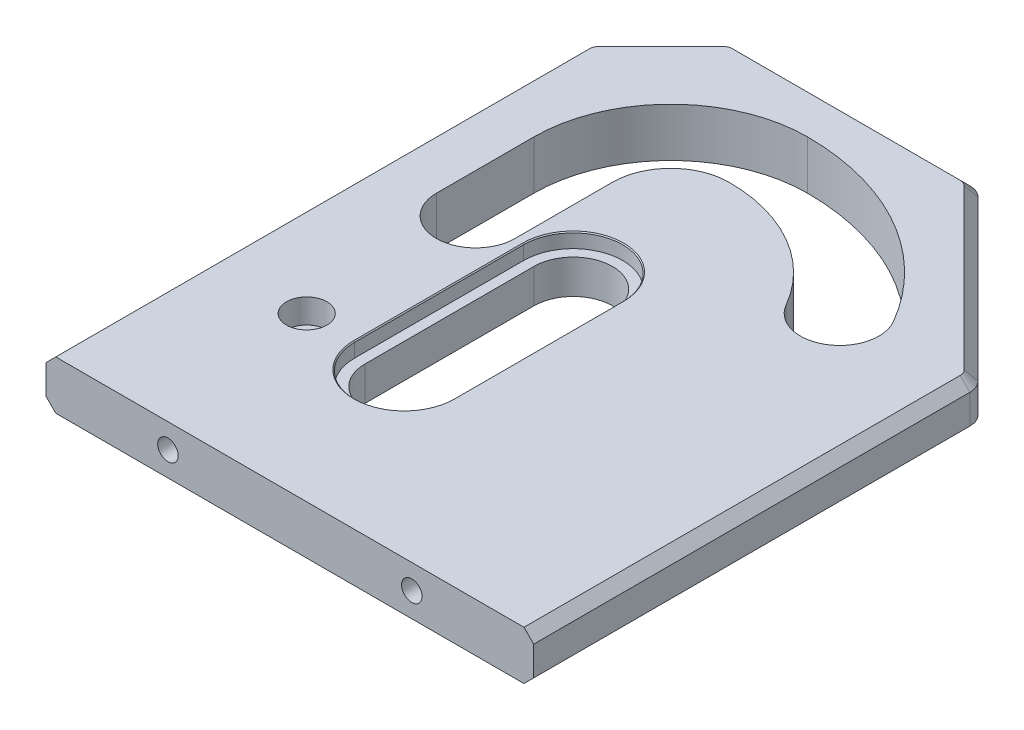
from build123d import *

# Parameters (mm, degrees)
SKETCH1_W                 = 100
SKETCH1_H                 = 126.094412
BOSS_EXTRUDE1_DEPTH       = 5
SLOTS_DEPTH               = 11
CUT_EXTRUDE5_DEPTH        = 3
CHAMFER2_SIZE             = 0.2
M5X0_8_TAPPED_HOLE2_D     = 4.2
SKETCH10_R                = 4.15
CUT_EXTRUDE4_DEPTH        = 5
M5X0_8_TAPPED_HOLE1_D     = 4.2
M5X0_8_TAPPED_HOLE1_DEPTH = 20
M5X0_8_TAPPED_HOLE1_TIP   = 1.2618073
CUT_EXTRUDE2_DEPTH        = 11
CUT_EXTRUDE3_DEPTH        = 11
FILLET1_R                 = 4
CHAMFER1_SIZE             = 2


with BuildPart() as part:
    # Sketch1 → Boss-Extrude1 (new body, symmetric)
    with BuildSketch(Plane(origin=(0, 0, 0), x_dir=(1, 0, 0), z_dir=(0, 1, 0))):
        with Locations((10, -5.047206)):
            Rectangle(SKETCH1_W, SKETCH1_H)
    extrude(amount=BOSS_EXTRUDE1_DEPTH, both=True)

    # Sketch3 → Slots (cut, through all)
    with BuildSketch(Plane(origin=(0, 5, 0), x_dir=(1, 0, 0), z_dir=(0, 1, 0))):
        with BuildLine():
            Line((-8.05, 0), (-8.05, -34.641016151))
            ThreePointArc((-8.05, -34.641016151), (0, -42.691016151), (8.05, -34.641016151))
            Line((8.05, -34.641016151), (8.05, 0))
            ThreePointArc((8.05, 0), (0, 8.05), (-8.05, 0))
        make_face()
        with BuildLine():
            Line((-11.95, 0), (-11.95, 20))
            ThreePointArc((-11.95, 20), (-8.449926035, 28.449926035), (0, 31.95))
            ThreePointArc((0, 31.95), (15.975, 27.669511651), (27.669511651, 15.975))
            ThreePointArc((27.669511651, 15.975), (38.666016151, 13.0284955), (41.612520652, 24.025))
            ThreePointArc((41.612520652, 24.025), (24.025, 41.612520652), (0, 48.05))
            ThreePointArc((0, 48.05), (-19.834345212, 39.834345212), (-28.05, 20))
            Line((-28.05, 20), (-28.05, 0))
            ThreePointArc((-28.05, 0), (-20, -8.05), (-11.95, 0))
        make_face()
    extrude(amount=-SLOTS_DEPTH, mode=Mode.SUBTRACT)

    # Sketch11 → Cut-Extrude5 (cut)
    with BuildSketch(Plane(origin=(0, 5, 0), x_dir=(1, 0, 0), z_dir=(0, 1, 0))):
        with BuildLine():
            Line((-10.15, 0), (-10.15, -34.641016151))
            ThreePointArc((-10.15, -34.641016151), (0, -44.791016151), (10.15, -34.641016151))
            Line((10.15, -34.641016151), (10.15, 0))
            ThreePointArc((10.15, 0), (0, 10.15), (-10.15, 0))
        make_face()
    extrude(amount=-CUT_EXTRUDE5_DEPTH, mode=Mode.SUBTRACT)

    # Chamfer2
    chamfer2_edges = [part.edges().sort_by_distance(p)[0] for p in [
        (0, 5, -10.15),
        (-10.15, 5, 17.320508076),
        (0, 5, 44.791016151),
        (10.15, 5, 17.320508076),
    ]]
    chamfer(chamfer2_edges, length=CHAMFER2_SIZE)

    # M5x0.8 Tapped Hole2 (through all)
    with Locations(Plane(origin=(0, 5, 0), x_dir=(1, 0, 0), z_dir=(0, 1, 0))):
        with Locations((-20, -34.641016151)):
            Hole(M5X0_8_TAPPED_HOLE2_D / 2)

    # Sketch10 → Cut-Extrude4 (cut)
    with BuildSketch(Plane(origin=(0, 5, 0), x_dir=(1, 0, 0), z_dir=(0, 1, 0))):
        with Locations((-20, -34.641016151)):
            Circle(SKETCH10_R)
    extrude(amount=-CUT_EXTRUDE4_DEPTH, mode=Mode.SUBTRACT)

    # M5x0.8 Tapped Hole1
    with Locations(Plane.XY.offset(68.094412)):
        with Locations((-15, 0), (35, 0)):
            Hole(M5X0_8_TAPPED_HOLE1_D / 2, depth=M5X0_8_TAPPED_HOLE1_DEPTH)
            with Locations((0, 0, -(M5X0_8_TAPPED_HOLE1_DEPTH + M5X0_8_TAPPED_HOLE1_TIP / 2))):  # 118° drill point
                Cone(0, M5X0_8_TAPPED_HOLE1_D / 2, M5X0_8_TAPPED_HOLE1_TIP, mode=Mode.SUBTRACT)

    # Sketch4 → Cut-Extrude2 (cut, through all)
    with BuildSketch(Plane(origin=(0, 5, 0), x_dir=(1, 0, 0), z_dir=(0, 1, 0))):
        Polygon((-40, 43), (-40, 58), (-25, 58), align=None)
    extrude(amount=-CUT_EXTRUDE2_DEPTH, mode=Mode.SUBTRACT)

    # Sketch5 → Cut-Extrude3 (cut, through all)
    with BuildSketch(Plane(origin=(0, 5, 0), x_dir=(1, 0, 0), z_dir=(0, 1, 0))):
        Polygon((25, 58), (60, 58), (60, 23), align=None)
    extrude(amount=-CUT_EXTRUDE3_DEPTH, mode=Mode.SUBTRACT)

    # Fillet1
    fillet1_edges = [part.edges().sort_by_distance(p)[0] for p in [
        (-25, 0, -58),
        (-40, 0, -43),
        (60, 0, -23),
        (25, 0, -58),
    ]]
    fillet(fillet1_edges, radius=FILLET1_R)

    # Chamfer1
    chamfer1_edges = [part.edges().sort_by_distance(p)[0] for p in [
        (60, 5, 23.375633125),
        (42.5, 5, -40.5),
        (0, 5, -58),
        (-32.5, 5, -50.5),
        (-40, 5, 13.375633125),
        (-39.69551813, 5, -42.87387948),
        (-24.87387948, 5, -57.69551813),
        (24.87387948, 5, -57.69551813),
        (59.69551813, 5, -22.87387948),
        (42.5, -5, -40.5),
        (-40, -5, 13.375633125),
        (-32.5, -5, -50.5),
        (0, -5, -58),
        (-39.69551813, -5, -42.87387948),
        (-24.87387948, -5, -57.69551813),
        (24.87387948, -5, -57.69551813),
        (59.69551813, -5, -22.87387948),
        (60, -5, 23.375633125),
    ]]
    chamfer(chamfer1_edges, length=CHAMFER1_SIZE)


solid = part.part
